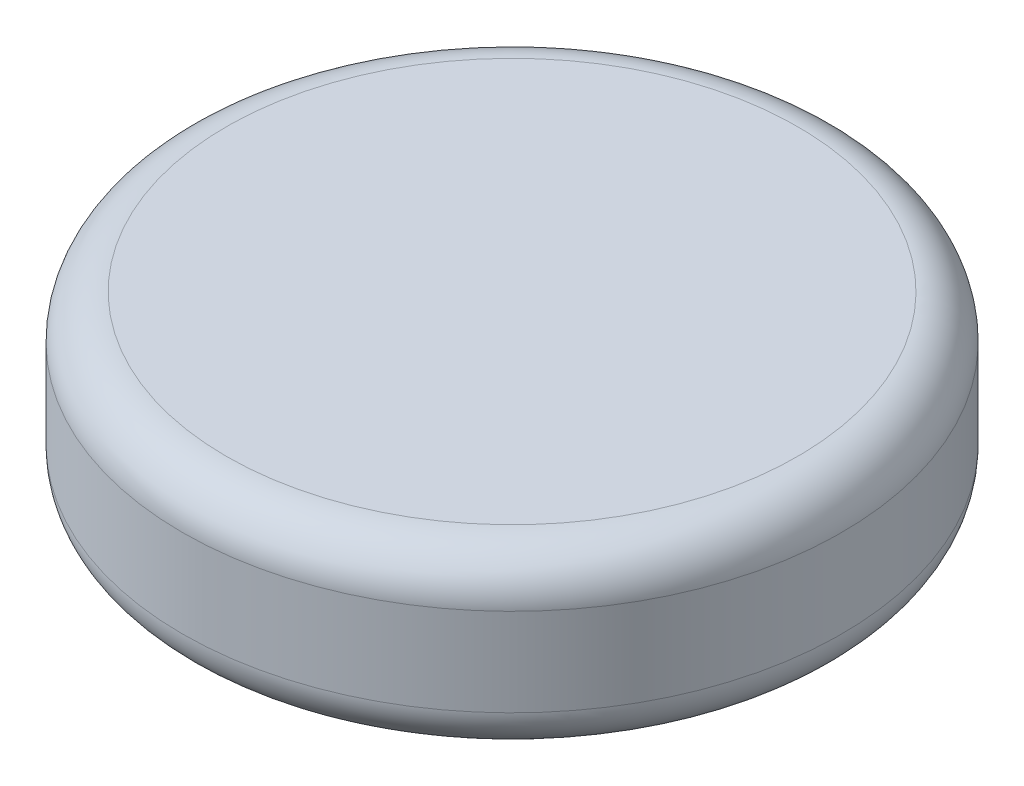
from build123d import *

# Parameters (mm, degrees)
SKETCH_1_R      = 7.5
EXTRUDE_1_DEPTH = 1.2
SKETCH_1_3_R    = 7.5
SKETCH_1_3_R_2  = 6.3
EXTRUDE_2_DEPTH = 4
SKETCH_1_5_W    = 6.2
SKETCH_1_5_H    = 6.2
EXTRUDE_3_DEPTH = 2
EXTRUDE_START   = -2
SKETCH_1_6_W    = 6.2
SKETCH_1_6_H    = 6.2
SKETCH_1_6_W_2  = 3.8
SKETCH_1_6_H_2  = 3.8
EXTRUDE_4_DEPTH = 3
FILLET_1_R      = 1
SKETCH_2_W      = 3.8
SKETCH_2_H      = 3.8
SKETCH_2_W_2    = 3.4
SKETCH_2_H_2    = 3.4
EXTRUDE_5_DEPTH = 0.8


with BuildPart() as part:
    # Sketch 1 → Extrude 1 (new body)
    with BuildSketch(Plane(origin=(0, 0, 0), x_dir=(1, 0, 0), z_dir=(0, 1, 0))):
        Circle(SKETCH_1_R)
    extrude(amount=-EXTRUDE_1_DEPTH)

    # Sketch 1_3 → Extrude 2 (add)
    with BuildSketch(Plane(origin=(0, 0, 0), x_dir=(1, 0, 0), z_dir=(0, 1, 0))):
        Circle(SKETCH_1_3_R)
        Circle(SKETCH_1_3_R_2, mode=Mode.SUBTRACT)
    extrude(amount=-EXTRUDE_2_DEPTH)

    # Sketch 1_5 → Extrude 3 (add)
    with BuildSketch(Plane(origin=(0, 0, 0), x_dir=(1, 0, 0), z_dir=(0, 1, 0))):
        Rectangle(SKETCH_1_5_W, SKETCH_1_5_H)
    extrude(amount=-EXTRUDE_3_DEPTH)

    # Sketch 1_6 → Extrude 4 (add)
    with BuildSketch(Plane(origin=(0, 0, 0), x_dir=(1, 0, 0), z_dir=(0, 1, 0)).offset(EXTRUDE_START)):
        Rectangle(SKETCH_1_6_W, SKETCH_1_6_H)
        Rectangle(SKETCH_1_6_W_2, SKETCH_1_6_H_2, mode=Mode.SUBTRACT)
    extrude(amount=-EXTRUDE_4_DEPTH)

    # Fillet 1
    fillet_1_edges = [part.edges().sort_by_distance(p)[0] for p in [
        (-7.5, 0, 0),
        (-7.5, -4, 0),
    ]]
    fillet(fillet_1_edges, radius=FILLET_1_R)

    # Sketch 2 → Extrude 5 (add)
    with BuildSketch(Plane.XZ.offset(5)):
        Rectangle(SKETCH_2_W, SKETCH_2_H)
        Rectangle(SKETCH_2_W_2, SKETCH_2_H_2, mode=Mode.SUBTRACT)
    extrude(amount=-EXTRUDE_5_DEPTH)


solid = part.part
